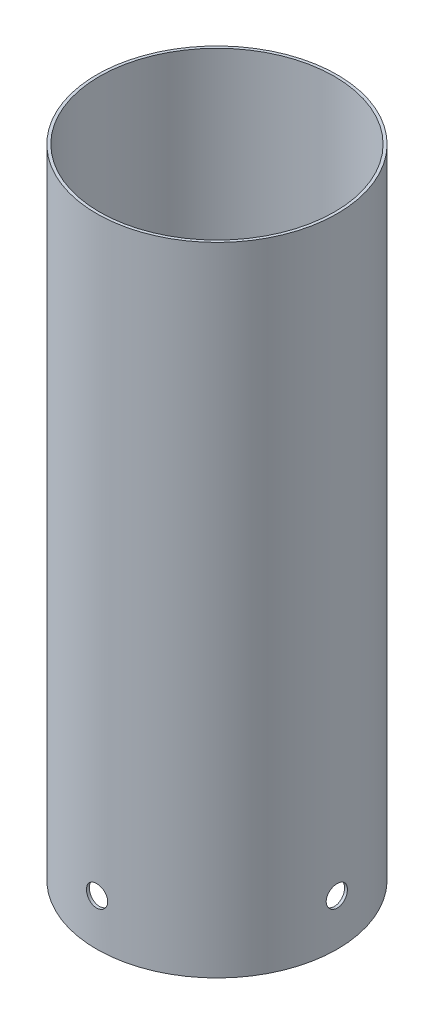
from build123d import *

# Parameters (mm, degrees)
SKETCH1_R           = 85
SKETCH1_R_2         = 83
EXTRUDE_THIN1_DEPTH = 450
SKETCH2_R           = 7.5
CUT_EXTRUDE1_DEPTH  = 100
CIRPATTERN1_COUNT   = 2
CIRPATTERN1_ANGLE   = 90


with BuildPart() as part:
    # Sketch1 → Extrude-Thin1 (new body)
    with BuildSketch(Plane(origin=(0, 0, 0), x_dir=(1, 0, 0), z_dir=(0, 1, 0))):
        Circle(SKETCH1_R)
        Circle(SKETCH1_R_2, mode=Mode.SUBTRACT)
    extrude(amount=EXTRUDE_THIN1_DEPTH)

    # Sketch2 → Cut-Extrude1 (cut, symmetric)
    with BuildSketch(Plane.XY):
        with Locations((0, 32.7)):
            Circle(SKETCH2_R)
    cut_extrude1 = extrude(amount=CUT_EXTRUDE1_DEPTH, both=True, mode=Mode.SUBTRACT)

    # CirPattern1: Cut-Extrude1 ×2 about axis
    cirpattern1_axis = Axis((0, 450, 0), (0, -1, 0))
    for i in range(1, CIRPATTERN1_COUNT):
        add(cut_extrude1.rotate(cirpattern1_axis, i * CIRPATTERN1_ANGLE / (CIRPATTERN1_COUNT - 1)), mode=Mode.SUBTRACT)


solid = part.part
